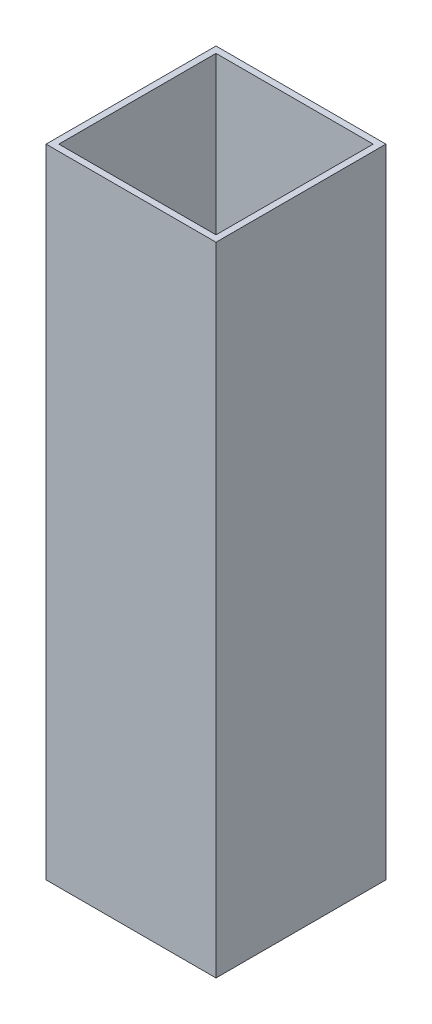
from build123d import *

# Parameters (mm, degrees)
ESBO_O1_W                = 40
ESBO_O1_H                = 40
RESSALTO_EXTRUS_O1_DEPTH = 150
ESBO_O2_W                = 37
ESBO_O2_H                = 37
CORTE_EXTRUS_O1_DEPTH    = 151


with BuildPart() as part:
    # Esboço1 → Ressalto-extrusão1 (new body)
    with BuildSketch(Plane(origin=(0, 0, 0), x_dir=(1, 0, 0), z_dir=(0, 1, 0))):
        Rectangle(ESBO_O1_W, ESBO_O1_H)
    extrude(amount=RESSALTO_EXTRUS_O1_DEPTH)

    # Esboço2 → Corte-extrusão1 (cut, through all)
    with BuildSketch(Plane.XZ):
        Rectangle(ESBO_O2_W, ESBO_O2_H)
    extrude(amount=-CORTE_EXTRUS_O1_DEPTH, mode=Mode.SUBTRACT)


solid = part.part
